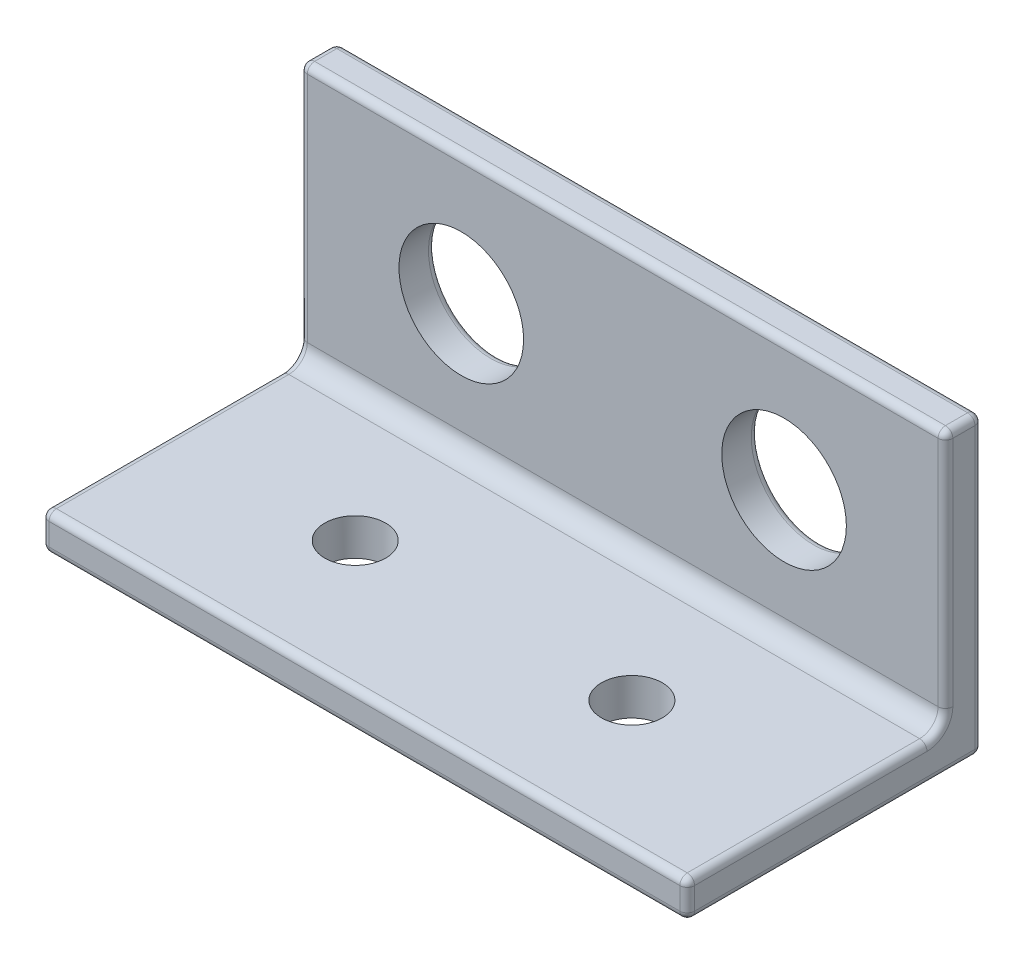
from build123d import *

# Parameters (mm, degrees)
MOUNT_DEPTH                  = 17.5
F_1_4_ANTENNA_HOLES_D        = 6.7564
SKETCH6_R                    = 1.65
M3_STANDOFF_HOLES_DEPTH      = 15
M3_STANDOFF_HOLES_DEPTH_BACK = 3
INSIDE_FILLET_R              = 1
EXTERNAL_FILLETS_R           = 0.4


with BuildPart() as part:
    # Sketch1 → Mount (new body, symmetric)
    with BuildSketch(Plane(origin=(0, 0, 0), x_dir=(0, 0, -1), z_dir=(1, 0, 0))):
        Polygon((-2, 16), (0, 16), (0, 0), (-16, 0), (-16, 2), (-2, 2), align=None)
    extrude(amount=MOUNT_DEPTH, both=True)

    # 1/4" Antenna Holes (through all)
    with Locations(Plane.XY.offset(2)):
        with Locations((-8.75, 9), (8.75, 9)):
            Hole(F_1_4_ANTENNA_HOLES_D / 2)

    # Sketch6 → M3 Standoff Holes (cut, two sides)
    with BuildSketch(Plane(origin=(0, 2, 0), x_dir=(1, 0, 0), z_dir=(0, 1, 0))) as m3_standoff_holes_sk:
        with Locations((-7.5, -9)):
            Circle(SKETCH6_R)
        with Locations((7.5, -9)):
            Circle(SKETCH6_R)
    extrude(amount=M3_STANDOFF_HOLES_DEPTH, mode=Mode.SUBTRACT)
    extrude(m3_standoff_holes_sk.sketch, amount=-M3_STANDOFF_HOLES_DEPTH_BACK, mode=Mode.SUBTRACT)

    # Inside Fillet
    inside_fillet_edges = [part.edges().sort_by_distance(p)[0] for p in [
        (0, 2, 2),
    ]]
    fillet(inside_fillet_edges, radius=INSIDE_FILLET_R)

    # External Fillets
    external_fillets_edges = [part.edges().sort_by_distance(p)[0] for p in [
        (0, 16, 2),
        (0, 16, 0),
        (0, 0, 0),
        (0, 0, 16),
        (0, 2, 16),
        (17.5, 1, 16),
        (17.5, 0, 8),
        (17.5, 8, 0),
        (12.1282, 9, 0),
        (17.5, 16, 1),
        (-5.3718, 9, 0),
        (-17.5, 2, 9.5),
        (17.5, 2, 9.5),
        (-17.5, 2.292893219, 2.292893219),
        (17.5, 2.292893219, 2.292893219),
        (17.5, 9.5, 2),
        (-17.5, 16, 1),
        (-17.5, 8, 0),
        (-17.5, 0, 8),
        (-17.5, 1, 16),
        (-17.5, 9.5, 2),
    ]]
    fillet(external_fillets_edges, radius=EXTERNAL_FILLETS_R)


solid = part.part
